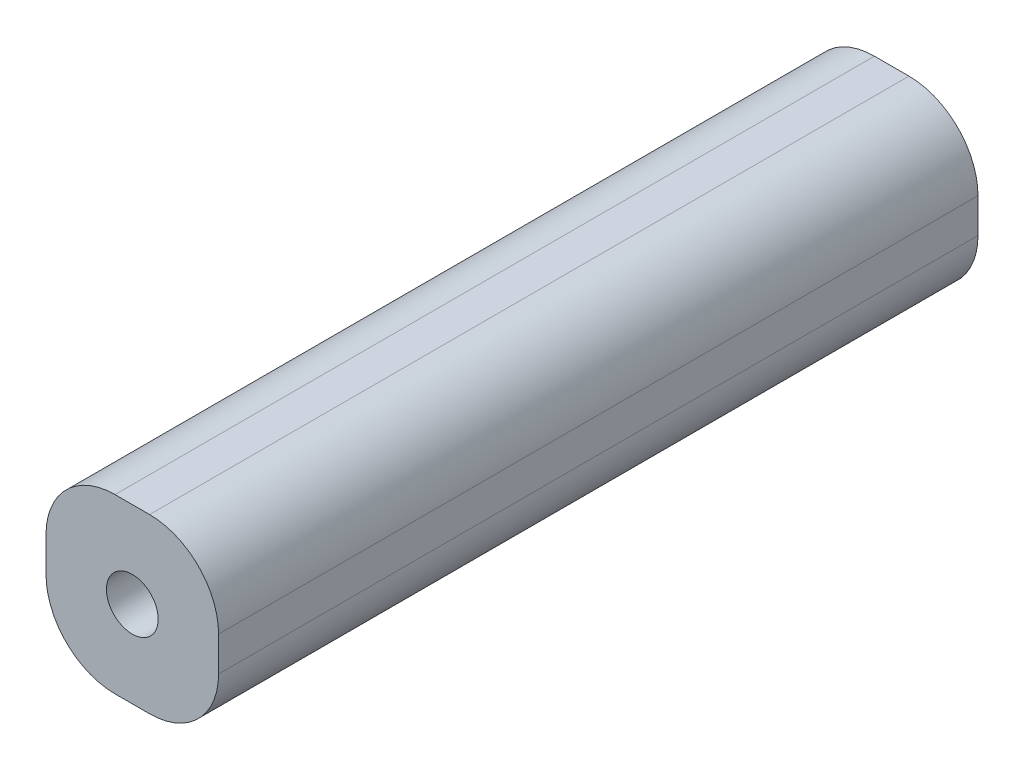
from build123d import *

# Parameters (mm, degrees)
SKETCH_1_W      = 10
SKETCH_1_H      = 10
SKETCH_1_R      = 1.5
EXTRUDE_1_DEPTH = 44
FILLET_1_R      = 4


with BuildPart() as part:
    # 草图1 → 凸台-拉伸1 (new body)
    with BuildSketch(Plane.XY):
        with Locations((-1.28, 2.34)):
            Rectangle(SKETCH_1_W, SKETCH_1_H)
        with Locations((-1.28, 2.34)):
            Circle(SKETCH_1_R, mode=Mode.SUBTRACT)
    extrude(amount=EXTRUDE_1_DEPTH)

    # 圆角1
    fillet_1_edges = [part.edges().sort_by_distance(p)[0] for p in [
        (3.72, -2.66, 22),
        (-6.28, -2.66, 22),
        (-6.28, 7.34, 22),
        (3.72, 7.34, 22),
    ]]
    fillet(fillet_1_edges, radius=FILLET_1_R)


solid = part.part
